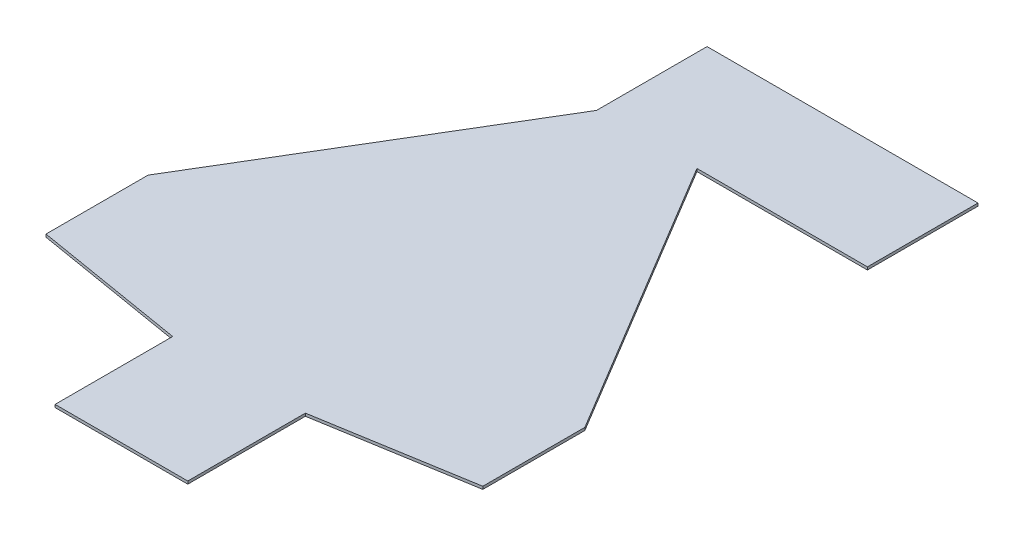
from build123d import *

# Parameters (mm, degrees)
BOSS_EXTRUDE1_DEPTH = 2.54


with BuildPart() as part:
    # Sketch1 → Boss-Extrude1 (new body)
    with BuildSketch(Plane(origin=(0, 0, 0), x_dir=(1, 0, 0), z_dir=(0, 1, 0))):
        Polygon((-177.243029513, -175.248335486), (-177.243029513, -269.013358426), (-37.543029513, -292.348386498), (-37.543029513, -400.386363558), (84.376970487, -400.386363558), (84.376970487, -292.348386498), (224.076970487, -269.013358426), (224.076970487, -175.248335486), (69.565481972, 82.213636442), (226.188459003, 82.213636442), (226.188459003, 183.813636442), (-22.731540997, 183.813636442), (-22.731540997, 82.213636442), align=None)
    extrude(amount=BOSS_EXTRUDE1_DEPTH)


solid = part.part
